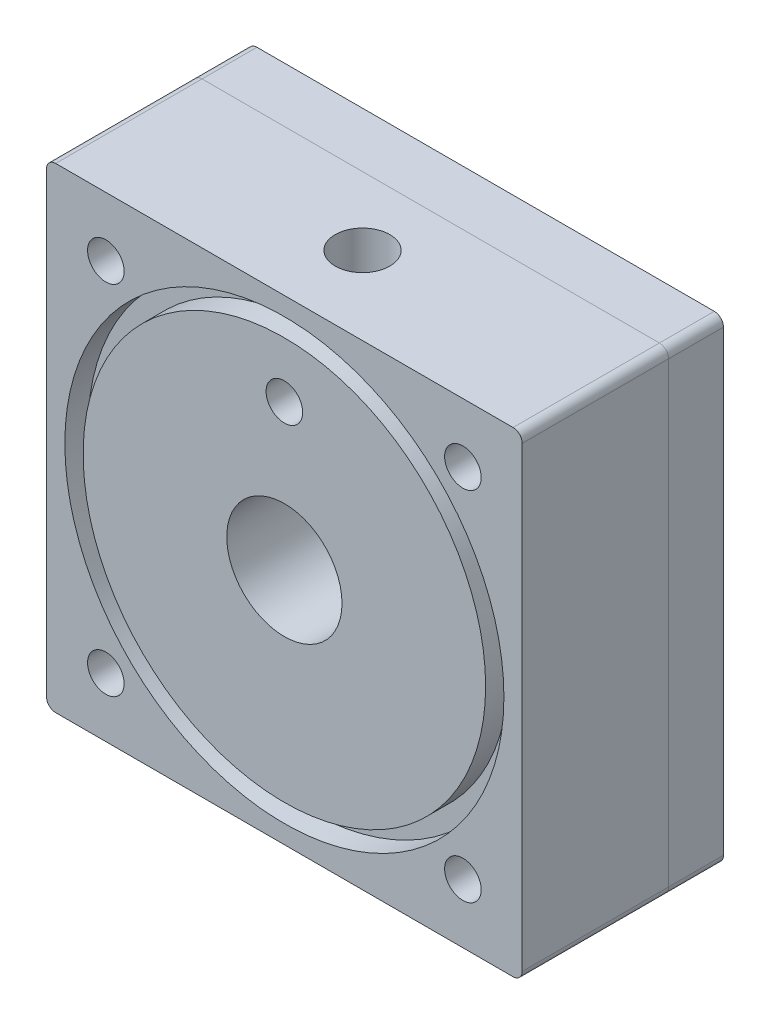
from build123d import *

# Parameters (mm, degrees)
SKETCH1_R                  = 40
SKETCH1_R_2                = 32
BOSS_EXTRUDE1_DEPTH        = 102.8
SKETCH1_3_R                = 32
SKETCH1_3_R_2              = 30
BOSS_EXTRUDE2_DEPTH        = 82.8
SKETCH1_4_R                = 30
SKETCH1_4_R_2              = 20
BOSS_EXTRUDE3_DEPTH        = 60.8
SKETCH1_5_W                = 165.1
SKETCH1_5_H                = 165.1
SKETCH1_5_R                = 6.35
SKETCH1_5_R_2              = 40
BOSS_EXTRUDE4_DEPTH        = 50.8
SKETCH2_R                  = 76.2
SKETCH2_R_2                = 69.85
CUT_EXTRUDE1_DEPTH         = 8
F_1_0MM_DOWEL_HOLE1_D      = 18.97
F_1_0MM_DOWEL_HOLE1_DEPTH  = 47.24
F_1_0MM_DOWEL_HOLE1_TIP    = 5.476167303
F_1_5MM_DOWEL_HOLE1_REACH  = 157.553
F_1_5MM_DOWEL_HOLE1_BORE_R = 6.35
SKETCH8_W                  = 165.1
SKETCH8_H                  = 165.1
SKETCH8_R                  = 6.35
BOSS_EXTRUDE5_DEPTH        = 19.05
FILLET1_R                  = 3.175
FILLET2_R                  = 3.175


with BuildPart() as part:
    # Sketch1 → Boss-Extrude1 (new body)
    with BuildSketch(Plane.XY):
        Circle(SKETCH1_R)
        Circle(SKETCH1_R_2, mode=Mode.SUBTRACT)
    extrude(amount=-BOSS_EXTRUDE1_DEPTH)

    # Sketch1_3 → Boss-Extrude2 (add)
    with BuildSketch(Plane.XY):
        Circle(SKETCH1_3_R)
        Circle(SKETCH1_3_R_2, mode=Mode.SUBTRACT)
    extrude(amount=-BOSS_EXTRUDE2_DEPTH)

    # Sketch1_4 → Boss-Extrude3 (add)
    with BuildSketch(Plane.XY):
        Circle(SKETCH1_4_R)
        Circle(SKETCH1_4_R_2, mode=Mode.SUBTRACT)
    extrude(amount=-BOSS_EXTRUDE3_DEPTH)

    # Sketch1_5 → Boss-Extrude4 (add)
    with BuildSketch(Plane.XY):
        Rectangle(SKETCH1_5_W, SKETCH1_5_H)
        with Locations((-61.963767235, -61.963767235)):
            Circle(SKETCH1_5_R, mode=Mode.SUBTRACT)
        with Locations((61.963767235, -61.963767235)):
            Circle(SKETCH1_5_R, mode=Mode.SUBTRACT)
        with Locations((61.963767235, 61.963767235)):
            Circle(SKETCH1_5_R, mode=Mode.SUBTRACT)
        with Locations((-61.963767235, 61.963767235)):
            Circle(SKETCH1_5_R, mode=Mode.SUBTRACT)
        Circle(SKETCH1_5_R_2, mode=Mode.SUBTRACT)
    extrude(amount=-BOSS_EXTRUDE4_DEPTH)

    # Sketch2 → Cut-Extrude1 (cut)
    with BuildSketch(Plane.XY):
        Circle(SKETCH2_R)
        Circle(SKETCH2_R_2, mode=Mode.SUBTRACT)
    extrude(amount=-CUT_EXTRUDE1_DEPTH, mode=Mode.SUBTRACT)

    # Ø1.0mm Dowel Hole1
    with Locations(Plane(origin=(0, 82.55, 0), x_dir=(1, 0, 0), z_dir=(0, 1, 0))):
        with Locations((0, 27.120400039)):
            Hole(F_1_0MM_DOWEL_HOLE1_D / 2, depth=F_1_0MM_DOWEL_HOLE1_DEPTH)
            with Locations((0, 0, -(F_1_0MM_DOWEL_HOLE1_DEPTH + F_1_0MM_DOWEL_HOLE1_TIP / 2))):  # 120° drill point
                Cone(0, F_1_0MM_DOWEL_HOLE1_D / 2, F_1_0MM_DOWEL_HOLE1_TIP, mode=Mode.SUBTRACT)

    # Ø1.5mm Dowel Hole1 bore → Ø1.5mm Dowel Hole1 (cut, up to next)
    with BuildSketch(Plane.XY, mode=Mode.PRIVATE) as f_1_5mm_dowel_hole1_sk1:
        with Locations((0, 50.55)):
            Circle(F_1_5MM_DOWEL_HOLE1_BORE_R)
    f_1_5mm_dowel_hole1_tool1 = extrude(f_1_5mm_dowel_hole1_sk1.sketch, amount=-F_1_5MM_DOWEL_HOLE1_REACH, mode=Mode.PRIVATE) & part.part
    add(f_1_5mm_dowel_hole1_tool1.solids().sort_by_distance((0, 50.55, 0))[0], mode=Mode.SUBTRACT)

    # Fillet1
    fillet1_edges = [part.edges().sort_by_distance(p)[0] for p in [
        (82.55, 82.55, -25.4),
        (82.55, -82.55, -25.4),
        (-82.55, -82.55, -25.4),
        (-82.55, 82.55, -25.4),
    ]]
    fillet(fillet1_edges, radius=FILLET1_R)


with BuildPart() as body_2:
    # Sketch8 → Boss-Extrude5 (new body)
    with BuildSketch(Plane(origin=(0, 0, -50.8), x_dir=(-1, 0, 0), z_dir=(0, 0, -1))):
        Rectangle(SKETCH8_W, SKETCH8_H)
        with Locations(Location((61.963767235, -61.963767235, 0), (0, 0, 180))):
            Circle(SKETCH8_R, mode=Mode.SUBTRACT)
        with Locations(Location((-61.963767235, -61.963767235, 0), (0, 0, 180))):
            Circle(SKETCH8_R, mode=Mode.SUBTRACT)
        with Locations(Location((-61.963767235, 61.963767235, 0), (0, 0, 180))):
            Circle(SKETCH8_R, mode=Mode.SUBTRACT)
        with Locations(Location((61.963767235, 61.963767235, 0), (0, 0, 180))):
            Circle(SKETCH8_R, mode=Mode.SUBTRACT)
    extrude(amount=BOSS_EXTRUDE5_DEPTH)

    # Fillet2
    fillet2_edges = [body_2.edges().sort_by_distance(p)[0] for p in [
        (-82.55, 82.55, -60.325),
        (-82.55, -82.55, -60.325),
        (82.55, -82.55, -60.325),
        (82.55, 82.55, -60.325),
    ]]
    fillet(fillet2_edges, radius=FILLET2_R)


solid = Compound([part.part, body_2.part])
